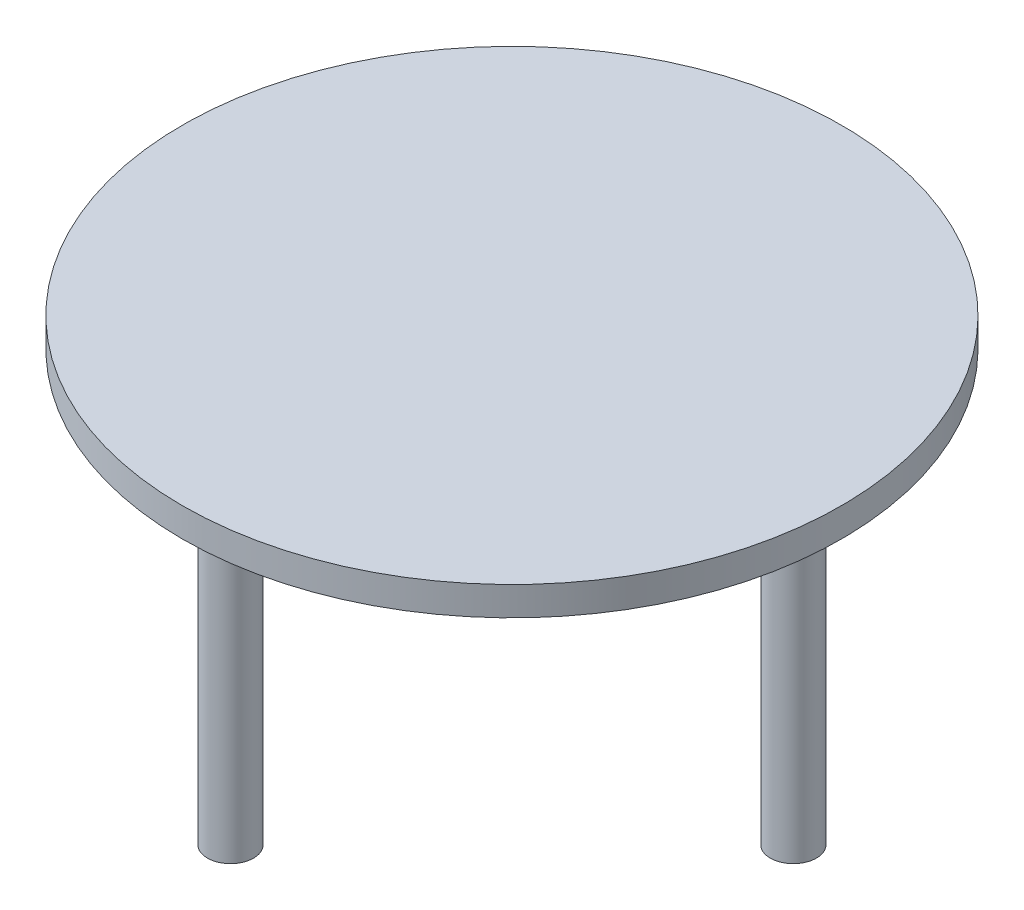
from build123d import *

# Parameters (mm, degrees)
IZIM2_R                     = 34.224414592
Y_KSEKLIK_EKSTR_ZYON6_DEPTH = 3
IZIM2_3_R                   = 2.396512678
Y_KSEKLIK_EKSTR_ZYON7_DEPTH = 30


with BuildPart() as part:
    # Çizim2 → Yükseklik-Ekstrüzyon6 (new body)
    with BuildSketch(Plane(origin=(0, 0, 0), x_dir=(1, 0, 0), z_dir=(0, 1, 0))):
        Circle(IZIM2_R)
    extrude(amount=Y_KSEKLIK_EKSTR_ZYON6_DEPTH)

    # Çizim2<3> → Yükseklik-Ekstrüzyon7 (add)
    with BuildSketch(Plane(origin=(0, 0, 0), x_dir=(1, 0, 0), z_dir=(0, 1, 0))):
        with Locations((0, 29.224414592)):
            Circle(IZIM2_3_R)
        with Locations((-29.224414592, 0)):
            Circle(IZIM2_3_R)
        with Locations((29.224414592, 0)):
            Circle(IZIM2_3_R)
        with Locations((0, -29.224414592)):
            Circle(IZIM2_3_R)
    extrude(amount=-Y_KSEKLIK_EKSTR_ZYON7_DEPTH)


solid = part.part
